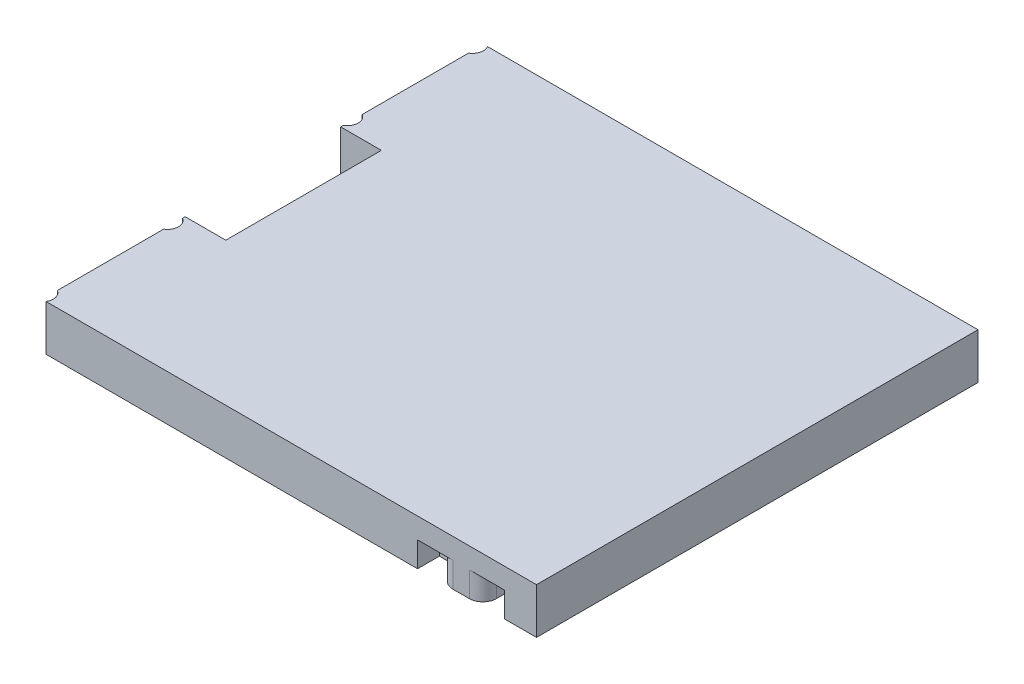
from build123d import *

# Parameters (mm, degrees)
SKETCH1_W           = 92.2
SKETCH1_H           = 81.1
BOSS_EXTRUDE1_DEPTH = 4.2
CUT_EXTRUDE1_DEPTH  = 4.6
CUT_EXTRUDE2_DEPTH  = 9.4
CUT_EXTRUDE3_DEPTH  = 9.4
SKETCH5_R           = 2.35
SKETCH5_R_2         = 1.9
CUT_EXTRUDE4_DEPTH  = 1.5
SKETCH6_W           = 1.4
SKETCH6_H           = 81.1
CUT_EXTRUDE5_DEPTH  = 9.4


with BuildPart() as part:
    # Sketch1 → Boss-Extrude1 (new body, symmetric)
    with BuildSketch(Plane(origin=(0, 0, 0), x_dir=(1, 0, 0), z_dir=(0, 1, 0))):
        Rectangle(SKETCH1_W, SKETCH1_H)
    extrude(amount=BOSS_EXTRUDE1_DEPTH, both=True)

    # Sketch2 → Cut-Extrude1 (cut)
    with BuildSketch(Plane.XZ.offset(4.2)):
        with BuildLine():
            Line((38.85, 40.55), (34.85, 40.55))
            Line((34.85, 40.55), (32.35, 40.55))
            ThreePointArc((32.35, 40.55), (34.117766953, 39.817766953), (34.85, 38.05))
            Line((34.85, 38.05), (34.85, 36.55))
            Line((34.85, 36.55), (38.85, 36.55))
            Line((38.85, 36.55), (38.85, 40.55))
        make_face()
        with BuildLine():
            Line((22.85, 36.55), (26.85, 36.55))
            Line((26.85, 36.55), (26.85, 38.05))
            ThreePointArc((26.85, 38.05), (27.582233047, 39.817766953), (29.35, 40.55))
            Line((29.35, 40.55), (26.85, 40.55))
            Line((26.85, 40.55), (22.85, 40.55))
            Line((22.85, 40.55), (22.85, 36.55))
        make_face()
        with BuildLine():
            Line((22.85, -36.55), (22.85, -40.55))
            Line((22.85, -40.55), (29.35, -40.55))
            ThreePointArc((29.35, -40.55), (27.582233047, -39.817766953), (26.85, -38.05))
            Line((26.85, -38.05), (26.85, -36.55))
            Line((26.85, -36.55), (22.85, -36.55))
        make_face()
        with BuildLine():
            Line((34.85, -36.55), (34.85, -38.05))
            ThreePointArc((34.85, -38.05), (34.117766953, -39.817766953), (32.35, -40.55))
            Line((32.35, -40.55), (38.85, -40.55))
            Line((38.85, -40.55), (38.85, -36.55))
            Line((38.85, -36.55), (34.85, -36.55))
        make_face()
    extrude(amount=-CUT_EXTRUDE1_DEPTH, mode=Mode.SUBTRACT)

    # Sketch3 → Cut-Extrude2 (cut, through all)
    with BuildSketch(Plane.XZ.offset(4.2)):
        with BuildLine():
            Line((45, 40.55), (46.1, 40.55))
            Line((46.1, 40.55), (46.1, 34.4))
            Line((46.1, 34.4), (45.5, 34.4))
            ThreePointArc((45.5, 34.4), (45.146446609, 34.546446609), (45, 34.9))
            Line((45, 34.9), (45, 40.55))
        make_face()
        with BuildLine():
            Line((46.1, -34.4), (46.1, -40.55))
            Line((46.1, -40.55), (45, -40.55))
            Line((45, -40.55), (45, -34.9))
            ThreePointArc((45, -34.9), (45.146446609, -34.546446609), (45.5, -34.4))
            Line((45.5, -34.4), (46.1, -34.4))
        make_face()
        with BuildLine():
            Line((-46.1, -37.767949192), (-46.1, -40.55))
            Line((-46.1, -40.55), (-45.397795547, -40.55))
            ThreePointArc((-45.397795547, -40.55), (-45.160817466, -39.010539992), (-46.1, -37.767949192))
        make_face()
        with BuildLine():
            Line((-46.1, -14.767949192), (-46.1, -18.232050808))
            ThreePointArc((-46.1, -18.232050808), (-45.1, -16.5), (-46.1, -14.767949192))
        make_face()
        with BuildLine():
            Line((-46.1, 18.232050808), (-46.1, 14.767949192))
            ThreePointArc((-46.1, 14.767949192), (-45.1, 16.5), (-46.1, 18.232050808))
        make_face()
        with BuildLine():
            Line((-45.397795547, 40.55), (-46.1, 40.55))
            Line((-46.1, 40.55), (-46.1, 37.767949192))
            ThreePointArc((-46.1, 37.767949192), (-45.160817466, 39.010539992), (-45.397795547, 40.55))
        make_face()
    extrude(amount=-CUT_EXTRUDE2_DEPTH, mode=Mode.SUBTRACT)

    # Sketch4 → Cut-Extrude3 (cut, through all)
    with BuildSketch(Plane.XZ.offset(4.2)):
        Polygon((-38.632, 11.8872), (-38.632, 12.2428), (-38.632, 14.2875), (-40.537, 14.2875), (-46.125, 14.2875), (-46.125, 13.6525), (-46.125, -14.2875), (-40.537, -14.2875), (-38.632, -14.2875), (-38.632, -12.2428), (-38.632, -11.8872), align=None)
    extrude(amount=-CUT_EXTRUDE3_DEPTH, mode=Mode.SUBTRACT)

    # Sketch5 → Cut-Extrude4 (cut)
    with BuildSketch(Plane.XZ.offset(4.2)):
        with Locations((41.25, -25)):
            Circle(SKETCH5_R)
        with Locations((41.25, 25)):
            Circle(SKETCH5_R)
        with Locations((19.5, 0)):
            Circle(SKETCH5_R)
        with Locations((-1.3, 15)):
            Circle(SKETCH5_R_2)
        with Locations((-1.3, -15)):
            Circle(SKETCH5_R_2)
        with Locations((-22.1, 0)):
            Circle(SKETCH5_R)
        with Locations((-43.85, -25)):
            Circle(SKETCH5_R)
        with Locations((-43.85, 25)):
            Circle(SKETCH5_R)
    extrude(amount=-CUT_EXTRUDE4_DEPTH, mode=Mode.SUBTRACT)

    # Sketch6 → Cut-Extrude5 (cut, through all)
    with BuildSketch(Plane.XZ.offset(4.2)):
        with Locations((45.4, 0)):
            Rectangle(SKETCH6_W, SKETCH6_H)
    extrude(amount=-CUT_EXTRUDE5_DEPTH, mode=Mode.SUBTRACT)


solid = part.part
